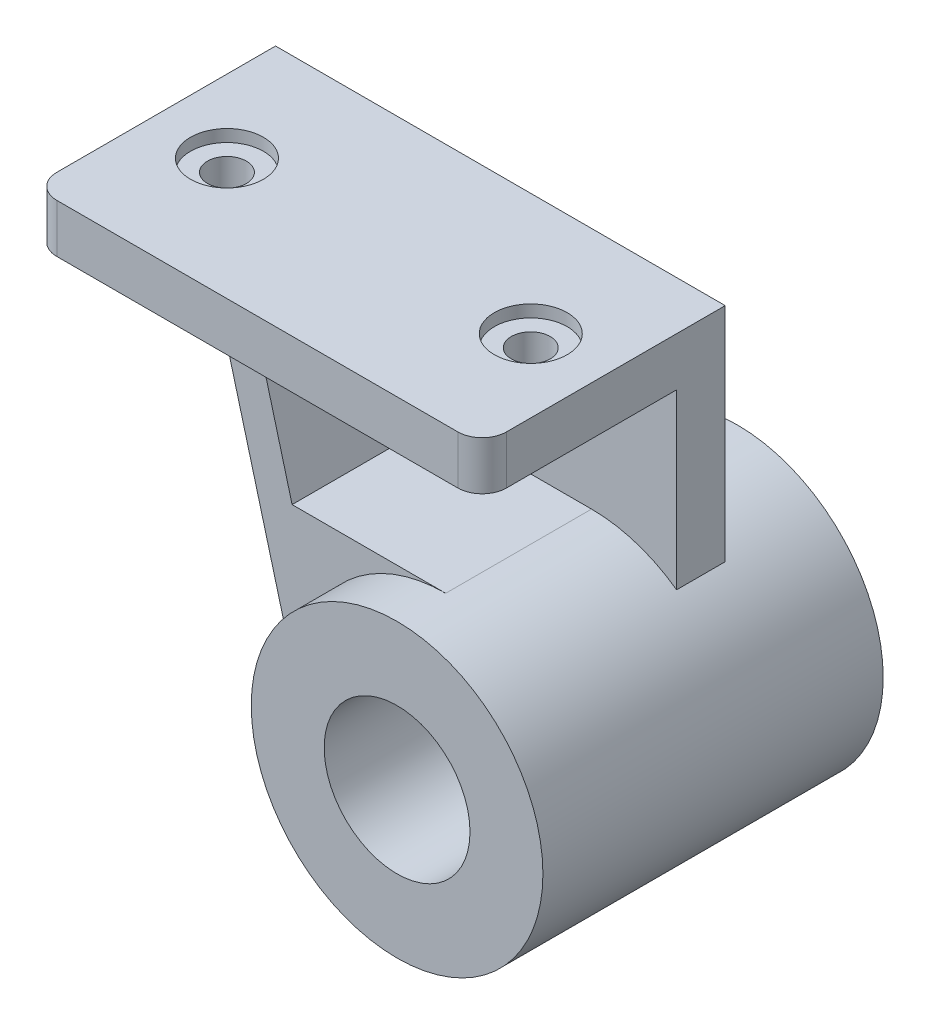
from build123d import *

# Parameters (mm, degrees)
SKETCH1_R                                 = 60
SKETCH1_R_2                               = 30
BOSS_EXTRUDE1_DEPTH                       = 70
BOSS_EXTRUDE4_DEPTH                       = 60
BOSS_EXTRUDE5_DEPTH                       = 20
BOSS_EXTRUDE6_DEPTH                       = 20
CBORE_FOR_M12_HEX_HEAD_SCREW1_D           = 16
CBORE_FOR_M12_HEX_HEAD_SCREW1_DEPTH       = 20
CBORE_FOR_M12_HEX_HEAD_SCREW1_CBORE_D     = 30
CBORE_FOR_M12_HEX_HEAD_SCREW1_CBORE_DEPTH = 5
CBORE_FOR_M12_HEX_HEAD_SCREW1_TIP         = 4.806884952


with BuildPart() as part:
    # Sketch1 → Boss-Extrude1 (new body, symmetric)
    with BuildSketch(Plane.XY):
        Circle(SKETCH1_R)
        Circle(SKETCH1_R_2, mode=Mode.SUBTRACT)
    extrude(amount=BOSS_EXTRUDE1_DEPTH, both=True)

    # Sketch4 → Boss-Extrude4 (add)
    with BuildSketch(Plane.XY.offset(50)):
        with BuildLine():
            Line((-94.270473916, 120), (-79.270473916, 120))
            Line((-79.270473916, 120), (-63.19352237, 60))
            Line((-63.19352237, 60), (0, 60))
            ThreePointArc((0, 60), (-47.601200417, 36.525685741), (-57.955549577, -15.529142706))
            Line((-57.955549577, -15.529142706), (-94.270473916, 120))
        make_face()
    extrude(amount=-BOSS_EXTRUDE4_DEPTH)

    # Sketch7 → Boss-Extrude5 (add)
    with BuildSketch(Plane(origin=(0, 0, -10), x_dir=(-1, 0, 0), z_dir=(0, 0, -1))):
        with BuildLine():
            Line((150, 120), (-35, 120))
            Line((-35, 120), (-35, 48.733971724))
            ThreePointArc((-35, 48.733971724), (41.47341809, 43.358454676), (50.240561153, -32.800701441))
            Line((50.240561153, -32.800701441), (150, 120))
        make_face()
    extrude(amount=BOSS_EXTRUDE5_DEPTH)

    # Sketch8 → Boss-Extrude6 (add)
    with BuildSketch(Plane(origin=(0, 120, 0), x_dir=(1, 0, 0), z_dir=(0, 1, 0))):
        with BuildLine():
            Line((-150, 30), (-150, -60))
            ThreePointArc((-150, -60), (-147.071067812, -67.071067812), (-140, -70))
            Line((-140, -70), (25, -70))
            ThreePointArc((25, -70), (32.071067812, -67.071067812), (35, -60))
            Line((35, -60), (35, 30))
            Line((35, 30), (-150, 30))
        make_face()
    extrude(amount=BOSS_EXTRUDE6_DEPTH)

    # CBORE for M12 Hex Head Screw1
    with Locations(Plane(origin=(0, 140, 0), x_dir=(1, 0, 0), z_dir=(0, 1, 0))):
        with Locations((-120, -20), (5, -20)):
            CounterBoreHole(CBORE_FOR_M12_HEX_HEAD_SCREW1_D / 2, CBORE_FOR_M12_HEX_HEAD_SCREW1_CBORE_D / 2, CBORE_FOR_M12_HEX_HEAD_SCREW1_CBORE_DEPTH, depth=CBORE_FOR_M12_HEX_HEAD_SCREW1_DEPTH)
            with Locations((0, 0, -(CBORE_FOR_M12_HEX_HEAD_SCREW1_DEPTH + CBORE_FOR_M12_HEX_HEAD_SCREW1_TIP / 2))):  # 118° drill point
                Cone(0, CBORE_FOR_M12_HEX_HEAD_SCREW1_D / 2, CBORE_FOR_M12_HEX_HEAD_SCREW1_TIP, mode=Mode.SUBTRACT)


solid = part.part
